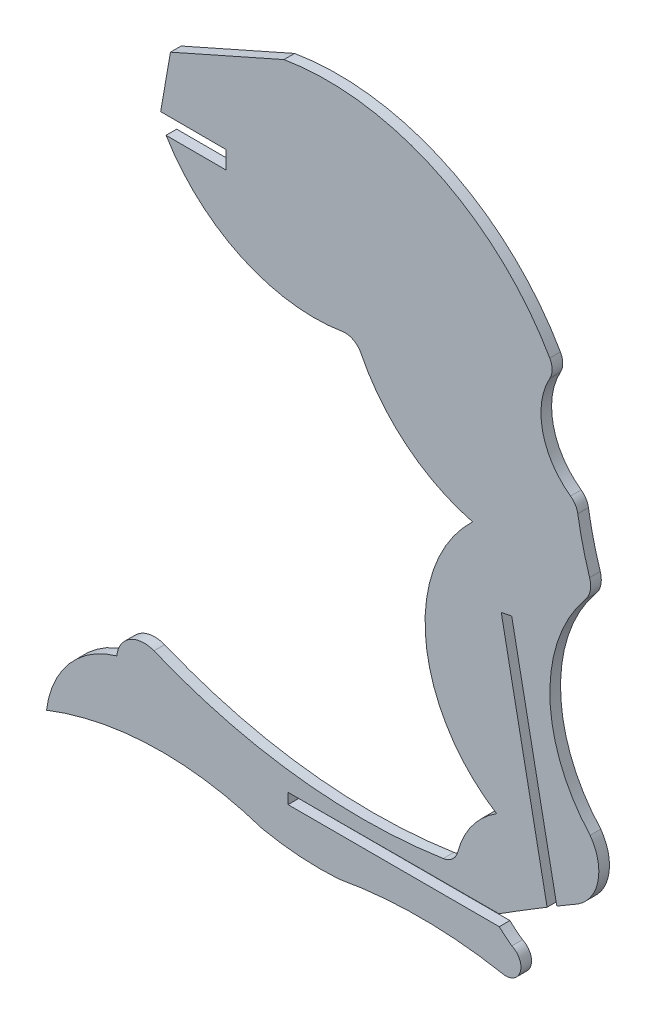
from build123d import *

# Parameters (mm, degrees)
BOSS_EXTRUDE1_DEPTH = 1.524


with BuildPart() as part:
    # Sketch1 → Boss-Extrude1 (new body)
    with BuildSketch(Plane.XY):
        with BuildLine():
            Line((211.523731391, 0), (211.523731391, -2.54))
            Line((211.523731391, -2.54), (202.922883793, -2.527561419))
            ThreePointArc((202.922883793, -2.527561419), (213.740389033, -12.255488314), (228.152940708, -14.237743463))
            ThreePointArc((228.152940708, -14.237743463), (229.717824369, -14.48375454), (230.832595731, -15.609217614))
            ThreePointArc((230.832595731, -15.609217614), (237.419060845, -23.79840587), (246.808881255, -28.518109213))
            ThreePointArc((246.808881255, -28.518109213), (240.118021125, -46.587905071), (250.249852394, -62.977875381))
            ThreePointArc((250.249852394, -62.977875381), (246.752221114, -66.207121421), (244.693512184, -70.499343702))
            ThreePointArc((244.693512184, -70.499343702), (243.933055031, -71.742181277), (242.614733859, -72.362640469))
            ThreePointArc((242.614733859, -72.362640469), (221.562461662, -72.654811524), (201.196110579, -67.316715223))
            ThreePointArc((201.196110579, -67.316715223), (197.716188185, -67.641087637), (195.87163248, -70.609705427))
            ThreePointArc((195.87163248, -70.609705427), (189.064028536, -74.973109583), (185.80791446, -82.374493805))
            ThreePointArc((185.80791446, -82.374493805), (201.196110579, -79.270242267), (216.71630717, -81.627455706))
            ThreePointArc((216.71630717, -81.627455706), (222.189556026, -82.374432464), (227.713542567, -82.374493805))
            ThreePointArc((227.713542567, -82.374493805), (239.353709896, -81.313035156), (250.993877225, -82.374493805))
            ThreePointArc((250.993877225, -82.374493805), (253.605845534, -80.999769877), (252.438715023, -78.288672185))
            ThreePointArc((252.438715023, -78.288672185), (251.512482649, -77.574775104), (250.632502883, -76.804586124))
            Line((250.632502883, -76.804586124), (220.3898048, -76.789947691))
            Line((220.3898048, -76.789947691), (220.3898048, -75.265947691))
            Line((220.3898048, -75.265947691), (250.581391322, -75.229531899))
            ThreePointArc((250.581391322, -75.229531899), (254.019892125, -73.080630034), (257.482403047, -70.97063356))
            Line((257.482403047, -70.97063356), (250.916170957, -37.690058187))
            Line((250.916170957, -37.690058187), (252.411347424, -37.395061012))
            Line((252.411347424, -37.395061012), (258.871697415, -70.138978964))
            ThreePointArc((258.871697415, -70.138978964), (260.416031898, -69.224443913), (261.964911432, -68.317627754))
            ThreePointArc((261.964911432, -68.317627754), (264.784241837, -63.996035266), (263.641101809, -58.964334117))
            ThreePointArc((263.641101809, -58.964334117), (257.882003246, -44.635324676), (262.978270283, -30.057403353))
            ThreePointArc((262.978270283, -30.057403353), (263.656491571, -28.633675993), (263.566043061, -27.059254582))
            ThreePointArc((263.566043061, -27.059254582), (262.588823269, -23.547314792), (261.873711132, -19.972780664))
            ThreePointArc((261.873711132, -19.972780664), (261.52305104, -19.036925788), (260.838506947, -18.308786906))
            ThreePointArc((260.838506947, -18.308786906), (256.845813142, -12.310330809), (257.874930037, -5.178430798))
            ThreePointArc((257.874930037, -5.178430798), (258.196394426, -3.928637169), (257.862228141, -2.682179643))
            ThreePointArc((257.862228141, -2.682179643), (241.665574941, 12.306611524), (219.801437593, 15.299091023))
            Line((219.801437593, 15.299091023), (203.553625304, 8.095778667))
            Line((203.553625304, 8.095778667), (202.1481549, 0.013558997))
            Line((202.1481549, 0.013558997), (211.523731391, 0))
        make_face()
    extrude(amount=BOSS_EXTRUDE1_DEPTH)


solid = part.part
